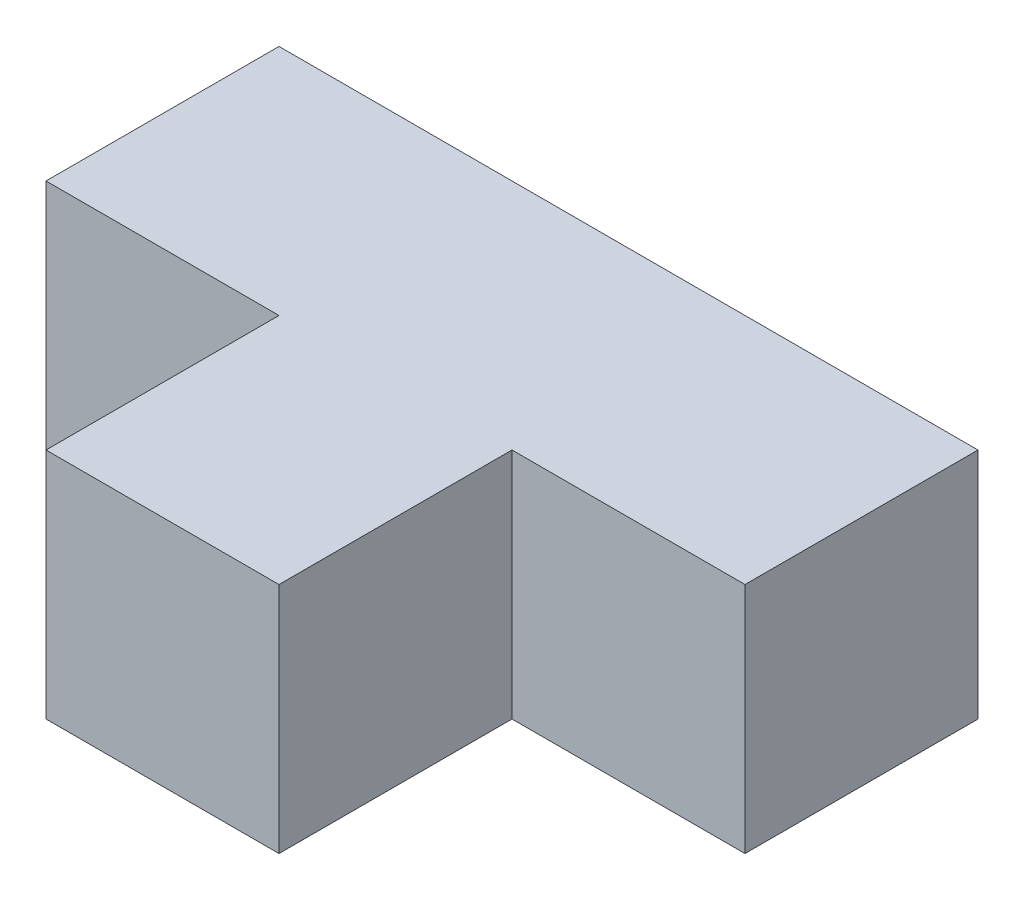
from build123d import *

# Parameters (mm, degrees)
SKETCH1_W           = 76.2
SKETCH1_H           = 50.8
BOSS_EXTRUDE1_DEPTH = 25.4
SKETCH2_W           = 25.4
SKETCH2_H           = 25.4
CUT_EXTRUDE1_DEPTH  = 26.4


with BuildPart() as part:
    # Sketch1 → Boss-Extrude1 (new body)
    with BuildSketch(Plane(origin=(0, 0, 0), x_dir=(1, 0, 0), z_dir=(0, 1, 0))):
        Rectangle(SKETCH1_W, SKETCH1_H)
    extrude(amount=BOSS_EXTRUDE1_DEPTH)

    # Sketch2 → Cut-Extrude1 (cut, through all)
    with BuildSketch(Plane(origin=(0, 25.4, 0), x_dir=(1, 0, 0), z_dir=(0, 1, 0))):
        with Locations((-25.4, -12.7)):
            Rectangle(SKETCH2_W, SKETCH2_H)
    cut_extrude1 = extrude(amount=-CUT_EXTRUDE1_DEPTH, mode=Mode.SUBTRACT)

    # Mirror1: Cut-Extrude1 across plane
    add(cut_extrude1.mirror(Plane(origin=(0, 0, 0), x_dir=(0, 0, 1), z_dir=(1, 0, 0))), mode=Mode.SUBTRACT)


solid = part.part
